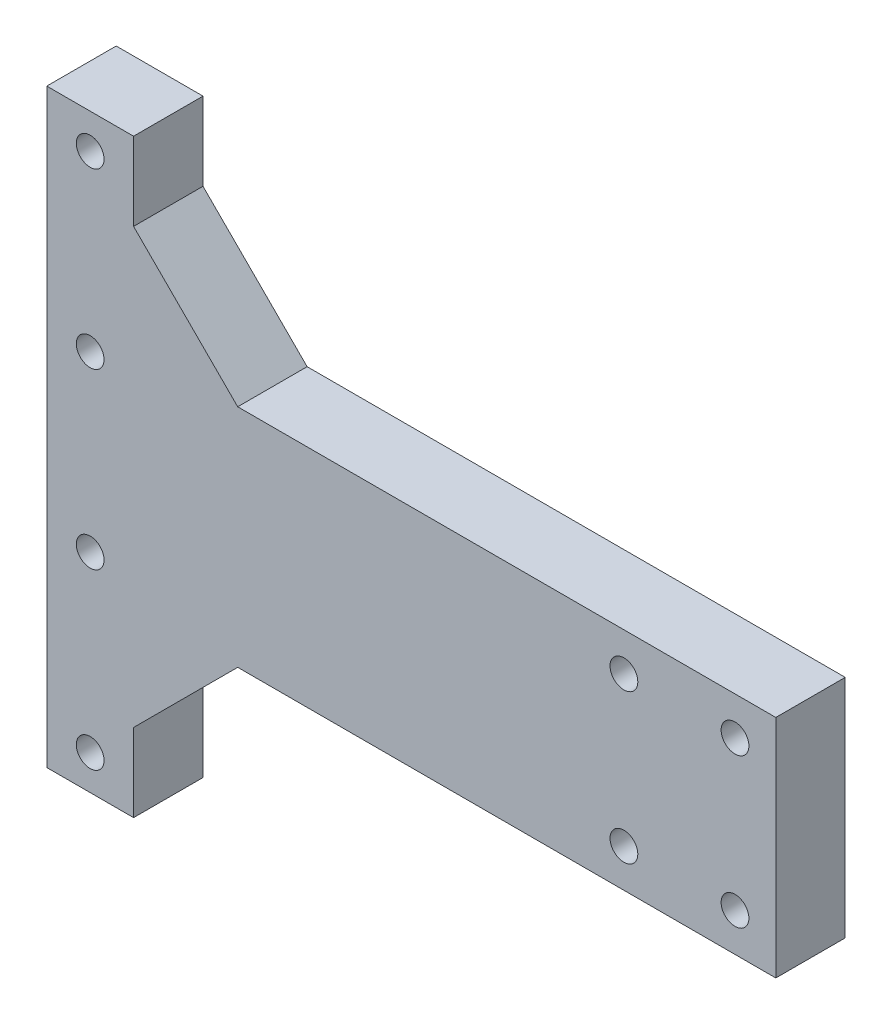
from build123d import *

# Parameters (mm, degrees)
BOSS_EXTRUDE1_DEPTH     = 40
SKETCH3_R               = 8
CUT_EXTRUDE1_DEPTH      = 233
CUT_EXTRUDE1_DEPTH_BACK = 172
SKETCH4_R               = 8
CUT_EXTRUDE2_DEPTH      = 81
CUT_EXTRUDE2_DEPTH_BACK = 192


with BuildPart() as part:
    # Sketch2 → Boss-Extrude1 (new body)
    with BuildSketch(Plane.XY):
        Polygon((0, 0), (0, 340), (50, 340), (50, 295), (110, 235), (420, 235), (420, 105), (110, 105), (50, 45), (50, 0), align=None)
    extrude(amount=BOSS_EXTRUDE1_DEPTH)

    # Sketch3 → Cut-Extrude1 (cut, two sides)
    with BuildSketch(Plane.XY.offset(40)) as cut_extrude1_sk:
        with Locations((25, 320)):
            Circle(SKETCH3_R)
        with Locations((25, 220)):
            Circle(SKETCH3_R)
        with Locations((25, 120)):
            Circle(SKETCH3_R)
        with Locations((25, 20)):
            Circle(SKETCH3_R)
    extrude(amount=CUT_EXTRUDE1_DEPTH, mode=Mode.SUBTRACT)
    extrude(cut_extrude1_sk.sketch, amount=-CUT_EXTRUDE1_DEPTH_BACK, mode=Mode.SUBTRACT)

    # Sketch4 → Cut-Extrude2 (cut, two sides)
    with BuildSketch(Plane.XY.offset(40)) as cut_extrude2_sk:
        with Locations((396.5, 213)):
            Circle(SKETCH4_R)
        with Locations((332.5, 213)):
            Circle(SKETCH4_R)
        with Locations((332.5, 127)):
            Circle(SKETCH4_R)
        with Locations((396.5, 127)):
            Circle(SKETCH4_R)
    extrude(amount=CUT_EXTRUDE2_DEPTH, mode=Mode.SUBTRACT)
    extrude(cut_extrude2_sk.sketch, amount=-CUT_EXTRUDE2_DEPTH_BACK, mode=Mode.SUBTRACT)


solid = part.part
